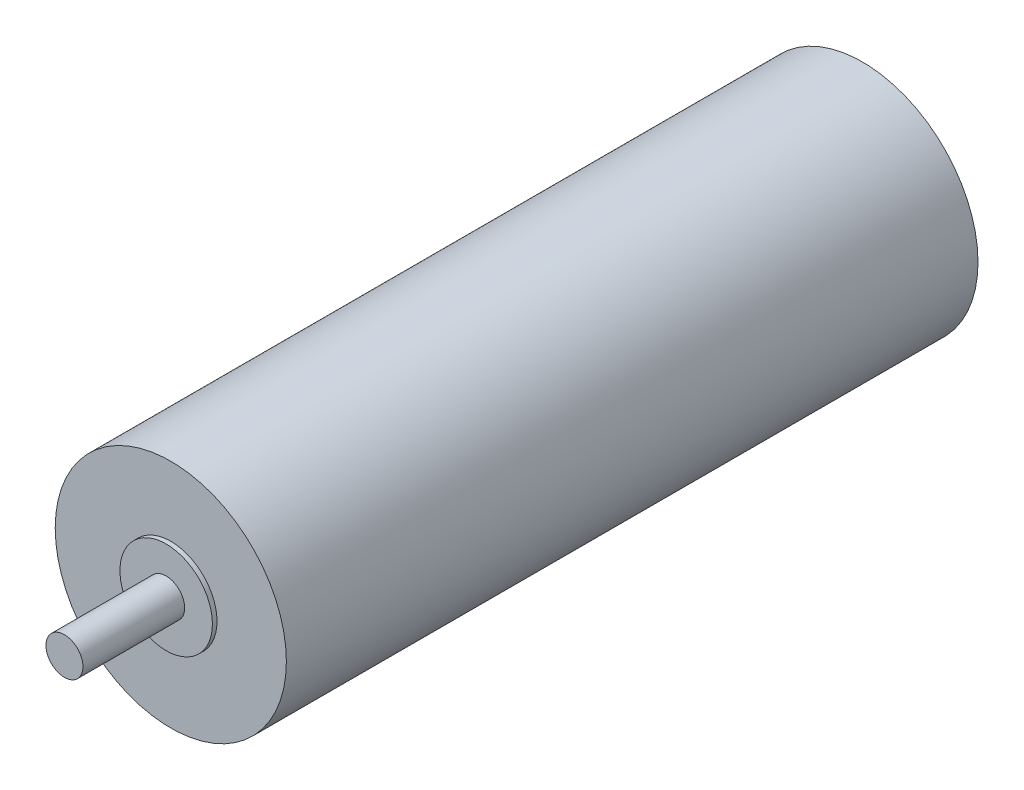
from build123d import *

# Parameters (mm, degrees)
SKETCH3_R           = 12.5
BOSS_EXTRUDE1_DEPTH = 74.8
SKETCH4_R           = 5
BOSS_EXTRUDE2_DEPTH = 0.5
SKETCH5_R           = 2
BOSS_EXTRUDE3_DEPTH = 11


with BuildPart() as part:
    # Sketch3 → Boss-Extrude1 (new body)
    with BuildSketch(Plane.XY):
        Circle(SKETCH3_R)
    extrude(amount=BOSS_EXTRUDE1_DEPTH)

    # Sketch4 → Boss-Extrude2 (add)
    with BuildSketch(Plane.XY.offset(74.8)):
        Circle(SKETCH4_R)
    extrude(amount=BOSS_EXTRUDE2_DEPTH)

    # Sketch5 → Boss-Extrude3 (add)
    with BuildSketch(Plane.XY.offset(75.3)):
        Circle(SKETCH5_R)
    extrude(amount=BOSS_EXTRUDE3_DEPTH)


solid = part.part
